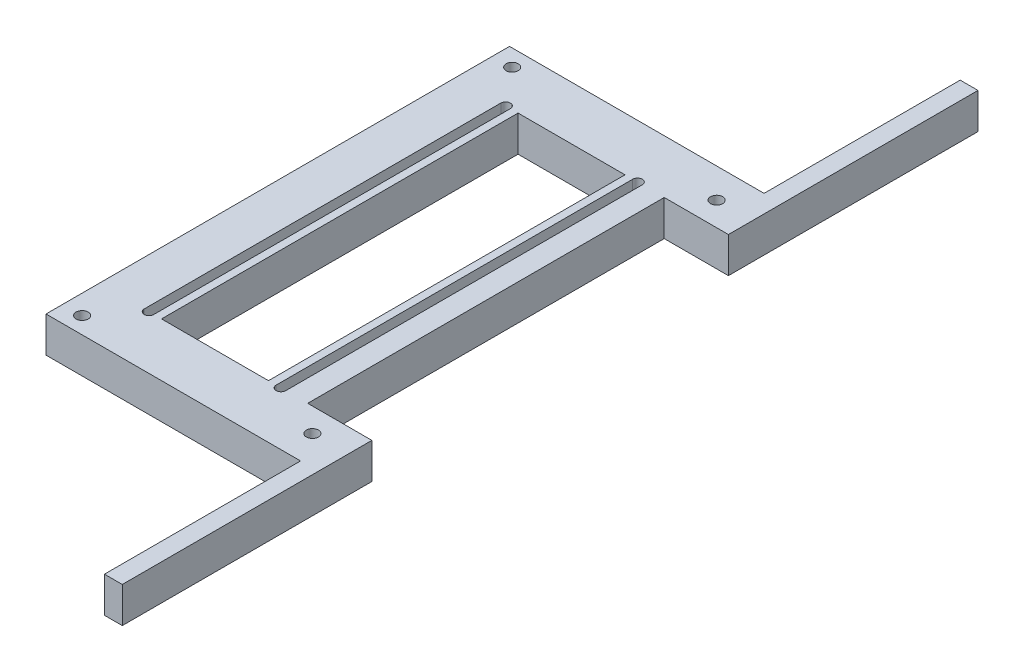
from build123d import *

# Parameters (mm, degrees)
SKETCH1_R           = 1.7
SKETCH1_W           = 30
SKETCH1_H           = 100
BOSS_EXTRUDE1_DEPTH = 10


with BuildPart() as part:
    # Sketch1 → Boss-Extrude1 (new body)
    with BuildSketch(Plane(origin=(0, 0, 0), x_dir=(1, 0, 0), z_dir=(0, 1, 0))):
        Polygon((32.234241277, 138.28125), (32.234241277, 68.28125), (14.234241277, 68.28125), (14.234241277, -31.71875), (32.234241277, -31.71875), (32.234241277, -101.71875), (27.234241277, -101.71875), (27.234241277, -46.71875), (-30.265758723, -46.71875), (-44.162144835, -46.71875), (-44.162144835, 83.28125), (-30.265758723, 83.28125), (27.234241277, 83.28125), (27.234241277, 138.28125), align=None)
        with Locations((22.234241277, 74.963265867)):
            Circle(SKETCH1_R, mode=Mode.SUBTRACT)
        with Locations((22.234241277, -38.400765867)):
            Circle(SKETCH1_R, mode=Mode.SUBTRACT)
        with Locations((-38.719051078, -42.025453022)):
            Circle(SKETCH1_R, mode=Mode.SUBTRACT)
        with Locations((-38.719051078, 78.587953022)):
            Circle(SKETCH1_R, mode=Mode.SUBTRACT)
        with Locations((-11.765758723, 18.28125)):
            Rectangle(SKETCH1_W, SKETCH1_H, mode=Mode.SUBTRACT)
        with BuildLine():
            Line((-31.615758723, 18.28125), (-31.615758723, 68.28125))
            ThreePointArc((-31.615758723, 68.28125), (-30.265758723, 69.63125), (-28.915758723, 68.28125))
            Line((-28.915758723, 68.28125), (-28.915758723, 18.28125))
            Line((-28.915758723, 18.28125), (-28.915758723, -31.71875))
            ThreePointArc((-28.915758723, -31.71875), (-30.265758723, -33.06875), (-31.615758723, -31.71875))
            Line((-31.615758723, -31.71875), (-31.615758723, 18.28125))
        make_face(mode=Mode.SUBTRACT)
        with BuildLine():
            Line((5.384241277, 18.28125), (5.384241277, 68.28125))
            ThreePointArc((5.384241277, 68.28125), (6.734241277, 69.63125), (8.084241277, 68.28125))
            Line((8.084241277, 68.28125), (8.084241277, 18.28125))
            Line((8.084241277, 18.28125), (8.084241277, -31.71875))
            ThreePointArc((8.084241277, -31.71875), (6.734241277, -33.06875), (5.384241277, -31.71875))
            Line((5.384241277, -31.71875), (5.384241277, 18.28125))
        make_face(mode=Mode.SUBTRACT)
    extrude(amount=BOSS_EXTRUDE1_DEPTH)


solid = part.part
